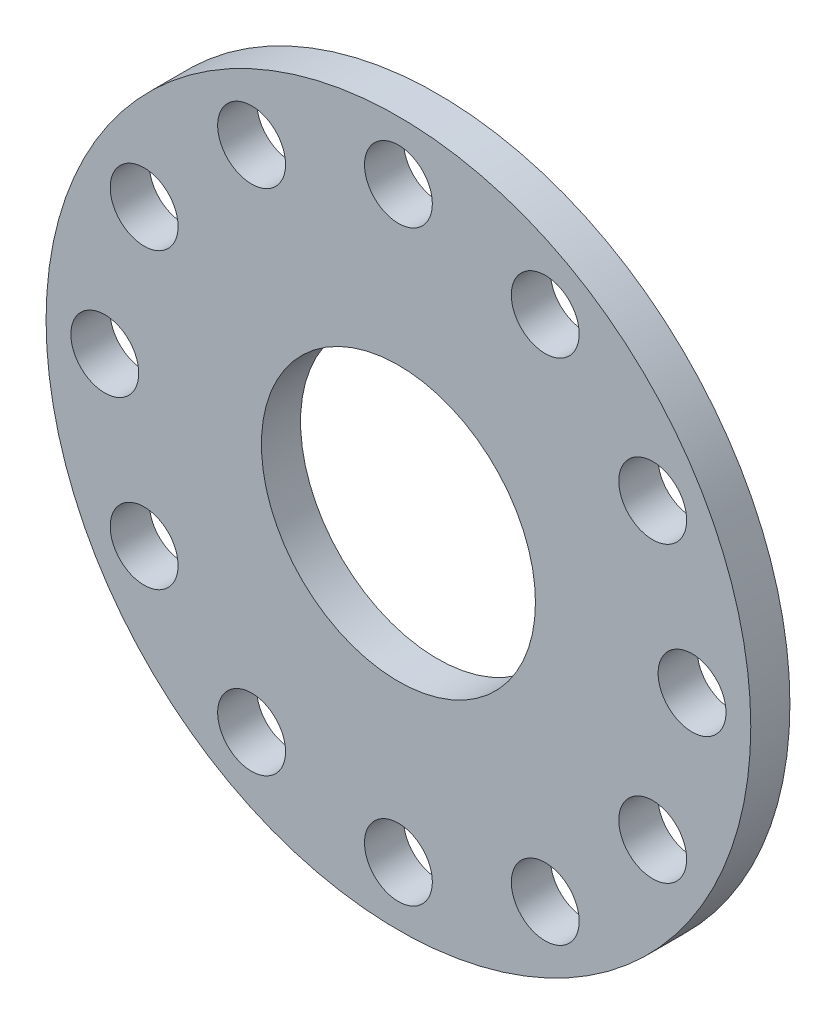
from build123d import *

# Parameters (mm, degrees)
SKETCH_1_R          = 27
SKETCH_1_R_2        = 10.5
SKETCH_1_R_3        = 2.6
EXTRUDE_1_DEPTH     = 3
SKETCH_3_R          = 2.6
CUT_EXTRUDE_2_DEPTH = 3


with BuildPart() as part:
    # 草图1 → 凸台-拉伸1 (new body)
    with BuildSketch(Plane.XY):
        Circle(SKETCH_1_R)
        Circle(SKETCH_1_R_2, mode=Mode.SUBTRACT)
        with Locations((0, 22.5)):
            Circle(SKETCH_1_R_3, mode=Mode.SUBTRACT)
        with Locations((19.485571585, 11.25)):
            Circle(SKETCH_1_R_3, mode=Mode.SUBTRACT)
        with Locations((19.485571585, -11.25)):
            Circle(SKETCH_1_R_3, mode=Mode.SUBTRACT)
        with Locations((0, -22.5)):
            Circle(SKETCH_1_R_3, mode=Mode.SUBTRACT)
        with Locations((-19.485571585, -11.25)):
            Circle(SKETCH_1_R_3, mode=Mode.SUBTRACT)
        with Locations((-19.485571585, 11.25)):
            Circle(SKETCH_1_R_3, mode=Mode.SUBTRACT)
    extrude(amount=EXTRUDE_1_DEPTH)

    # 草图3 → 切除-拉伸2 (cut)
    with BuildSketch(Plane.XY.offset(3)):
        with Locations((11.25, 19.485571585)):
            Circle(SKETCH_3_R)
        with Locations((22.5, 0)):
            Circle(SKETCH_3_R)
        with Locations((11.25, -19.485571585)):
            Circle(SKETCH_3_R)
        with Locations((-11.25, -19.485571585)):
            Circle(SKETCH_3_R)
        with Locations((-22.5, 0)):
            Circle(SKETCH_3_R)
        with Locations((-11.25, 19.485571585)):
            Circle(SKETCH_3_R)
    extrude(amount=-CUT_EXTRUDE_2_DEPTH, mode=Mode.SUBTRACT)


solid = part.part
